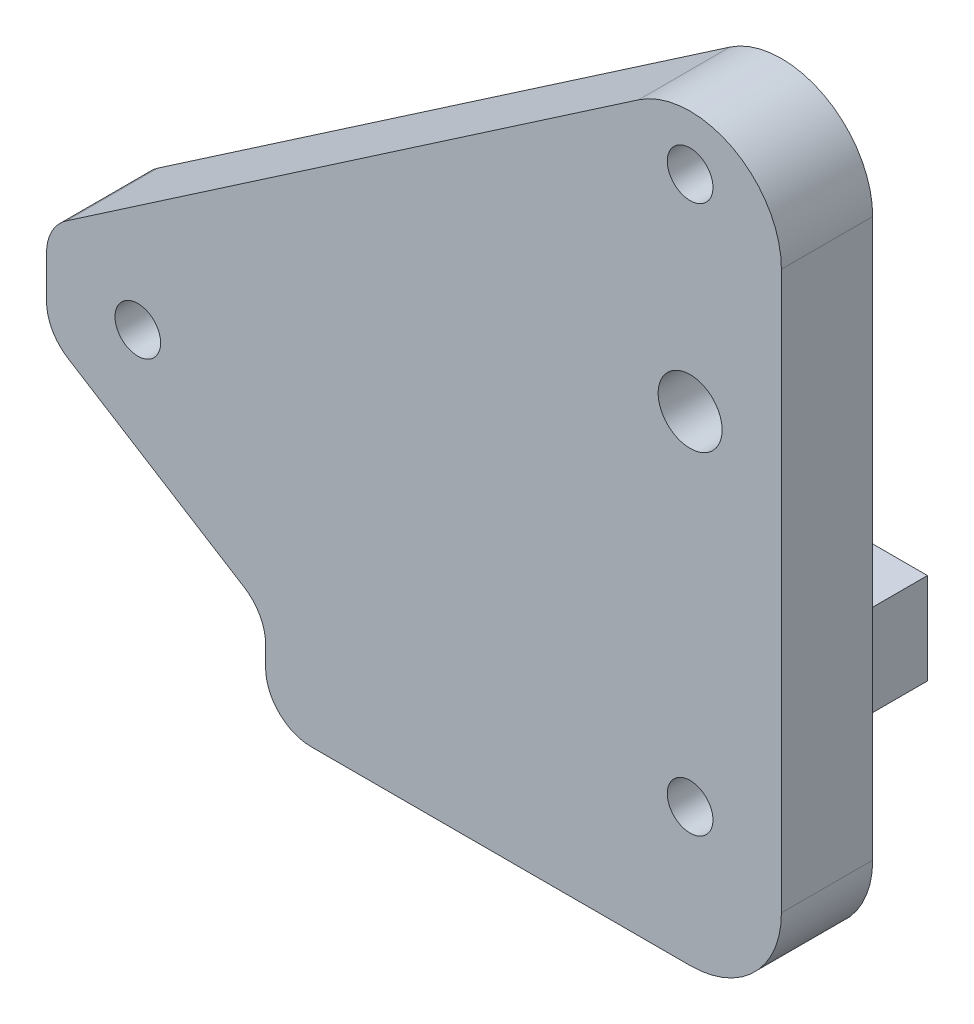
from build123d import *

# Parameters (mm, degrees)
SKETCH1_R           = 3.5
SKETCH1_R_2         = 2.5
BOSS_EXTRUDE1_DEPTH = 10
BOSS_EXTRUDE2_START = -10
BOSS_EXTRUDE2_DEPTH = 30
SKETCH4_R           = 5.25
SKETCH4_R_2         = 1.75
CUT_EXTRUDE1_DEPTH  = 11


with BuildPart() as part:
    # Sketch1 → Boss-Extrude1 (new body)
    with BuildSketch(Plane.XY):
        with BuildLine():
            Line((-15.641322365, 26.747479642), (-78.320661183, -16.076913339))
            ThreePointArc((-78.320661183, -16.076913339), (-79.921725111, -17.87116616), (-80.5, -20.205335615))
            Line((-80.5, -20.205335615), (-80.5, -24.794664385))
            ThreePointArc((-80.5, -24.794664385), (-79.873212406, -27.218507047), (-78.1499947, -29.034655905))
            Line((-78.1499947, -29.034655905), (-58.8500053, -41.09714928))
            ThreePointArc((-58.8500053, -41.09714928), (-57.126787594, -42.913298138), (-56.5, -45.3371408))
            Line((-56.5, -45.3371408), (-56.5, -47.565902593))
            ThreePointArc((-56.5, -47.565902593), (-55.035533906, -51.101436499), (-51.5, -52.565902593))
            Line((-51.5, -52.565902593), (-10, -52.565902593))
            ThreePointArc((-10, -52.565902593), (-2.928932188, -49.636970404), (0, -42.565902593))
            Line((0, -42.565902593), (0, 18.490635089))
            ThreePointArc((0, 18.490635089), (-5.331661091, 27.334085311), (-15.641322365, 26.747479642))
        make_face()
        with Locations((-10, 0)):
            Circle(SKETCH1_R, mode=Mode.SUBTRACT)
        with Locations((-10, 22.5)):
            Circle(SKETCH1_R_2, mode=Mode.SUBTRACT)
        with Locations((-70.5, -22.5)):
            Circle(SKETCH1_R_2, mode=Mode.SUBTRACT)
        with Locations((-10, -37.5)):
            Circle(SKETCH1_R_2, mode=Mode.SUBTRACT)
    extrude(amount=BOSS_EXTRUDE1_DEPTH)

    # Sketch3 → Boss-Extrude2 (add)
    with BuildSketch(Plane.XY.offset(10).offset(BOSS_EXTRUDE2_START)):
        with BuildLine():
            Line((-24, -52.565902593), (-51.5, -52.565902593))
            ThreePointArc((-51.5, -52.565902593), (-55.035533906, -51.101436499), (-56.5, -47.565902593))
            Line((-56.5, -47.565902593), (-56.5, -42.565902593))
            Line((-56.5, -42.565902593), (-24, -42.565902593))
            Line((-24, -42.565902593), (-24, -52.565902593))
        make_face()
    extrude(amount=-BOSS_EXTRUDE2_DEPTH)

    # Sketch4 → Cut-Extrude1 (cut, through all)
    with BuildSketch(Plane(origin=(0, -42.565902593, 0), x_dir=(1, 0, 0), z_dir=(0, 1, 0))):
        with Locations((-40.25, 15)):
            Circle(SKETCH4_R)
        with Locations((-40.25, 23)):
            Circle(SKETCH4_R_2)
        with Locations((-48.25, 15)):
            Circle(SKETCH4_R_2)
        with Locations((-32.25, 15)):
            Circle(SKETCH4_R_2)
        with Locations((-40.25, 7)):
            Circle(SKETCH4_R_2)
    extrude(amount=-CUT_EXTRUDE1_DEPTH, mode=Mode.SUBTRACT)


solid = part.part
